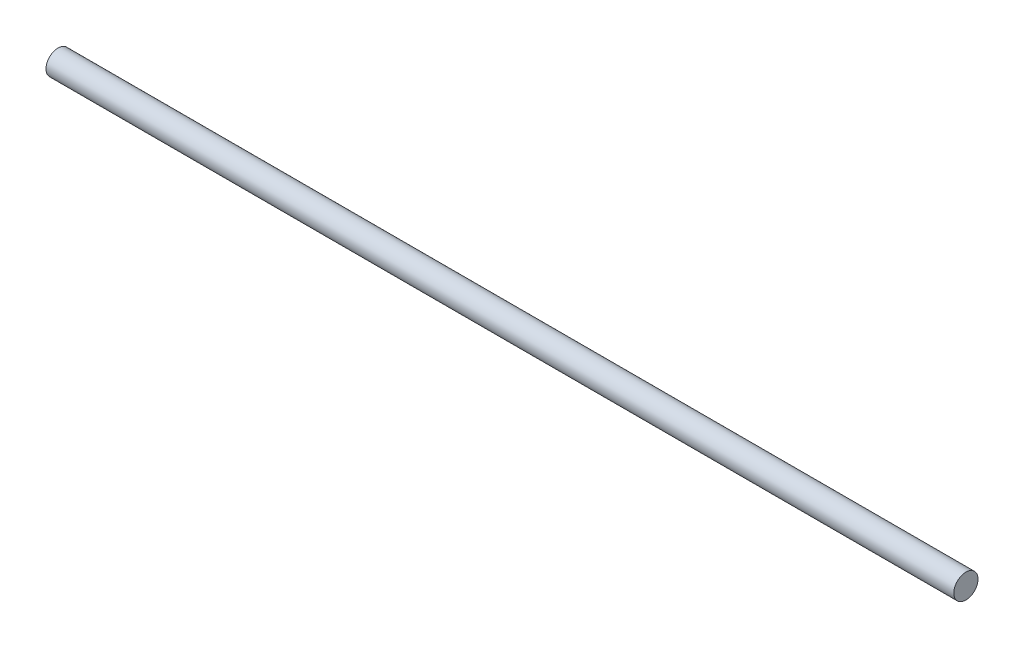
from build123d import *

# Parameters (mm, degrees)
BOSS_EXTRUDE1_DEPTH      = 150
BOSS_EXTRUDE1_DEPTH_BACK = 150
SKETCH1_R                = 4


with BuildPart() as part:
    # Sketch1 → Boss-Extrude1 (new, two sides: drawn at the far end of the back side and taken through both)
    with BuildSketch(Plane(origin=(0, 0, 0), x_dir=(0, 0, -1), z_dir=(1, 0, 0)).offset(-BOSS_EXTRUDE1_DEPTH_BACK)):
        Circle(SKETCH1_R)
    extrude(amount=BOSS_EXTRUDE1_DEPTH + BOSS_EXTRUDE1_DEPTH_BACK)


solid = part.part
